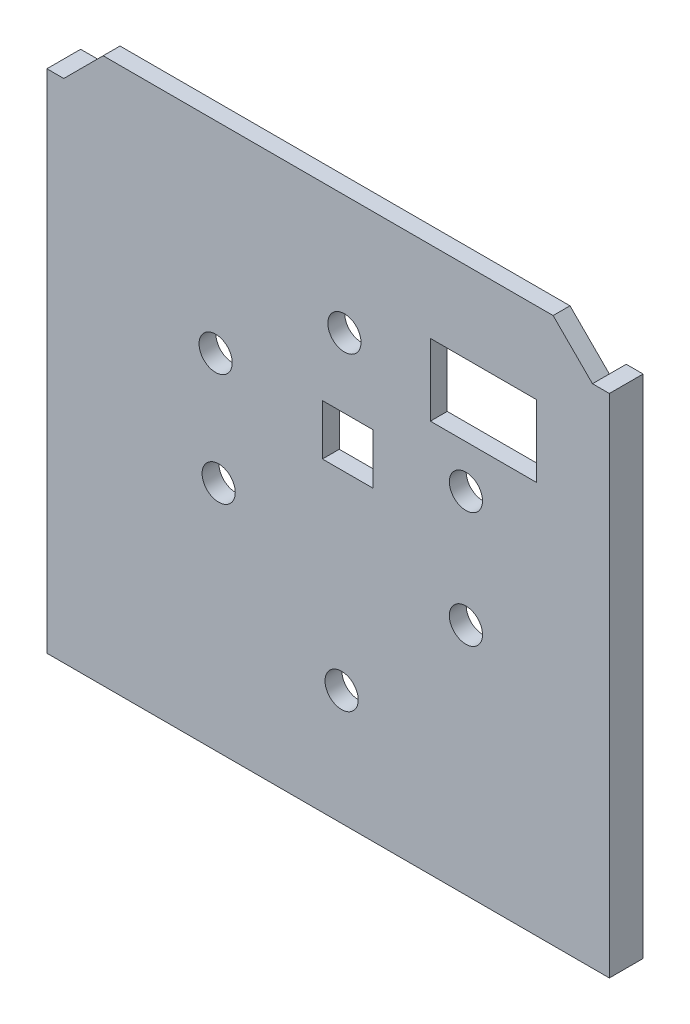
from build123d import *

# Parameters (mm, degrees)
CROQUIS1_R              = 2.950001172
CROQUIS1_W              = 9
CROQUIS1_H              = 9
CROQUIS1_W_2            = 18.849999644
CROQUIS1_H_2            = 12.749999762
SALIENTE_EXTRUIR1_DEPTH = 3
SALIENTE_EXTRUIR6_DEPTH = 3


with BuildPart() as part:
    # Croquis1 → Saliente-Extruir1 (new body)
    with BuildSketch(Plane.XY.offset(-0.156260387)):
        Polygon((51.261125499, 62.988673094), (44.261125499, 69.988673094), (-35.738874501, 69.988673094), (-42.738874501, 62.988673094), (-45.738874501, 62.988673094), (-45.738874501, -27.011326906), (54.261125499, -27.011326906), (54.261125499, 62.988673094), align=None)
        with Locations((7.161124531, 48.770443145)):
            Circle(CROQUIS1_R, mode=Mode.SUBTRACT)
        with Locations((28.761125092, 35.170443896)):
            Circle(CROQUIS1_R, mode=Mode.SUBTRACT)
        with Locations((28.761125092, 14.5704435)):
            Circle(CROQUIS1_R, mode=Mode.SUBTRACT)
        with Locations((6.661127243, -6.529559074)):
            Circle(CROQUIS1_R, mode=Mode.SUBTRACT)
        with Locations((-15.198872503, 14.470443669)):
            Circle(CROQUIS1_R, mode=Mode.SUBTRACT)
        with Locations((-15.738875683, 34.170445595)):
            Circle(CROQUIS1_R, mode=Mode.SUBTRACT)
        with Locations((7.748576734, 31.892113927)):
            Rectangle(CROQUIS1_W, CROQUIS1_H, mode=Mode.SUBTRACT)
        with Locations((31.861125879, 49.188674036)):
            Rectangle(CROQUIS1_W_2, CROQUIS1_H_2, mode=Mode.SUBTRACT)
    extrude(amount=SALIENTE_EXTRUIR1_DEPTH)

    # Croquis9 → Saliente-Extruir6 (add)
    with BuildSketch(Plane(origin=(0, 0, -0.156260387), x_dir=(-1, 0, 0), z_dir=(0, 0, -1))):
        Polygon((-54.261125499, 62.988673094), (-51.261125499, 62.988673094), (-51.261125499, -24.011326906), (42.738874501, -24.011326906), (42.738874501, 62.988673094), (45.738874501, 62.988673094), (45.738874501, -27.011326906), (-54.261125499, -27.011326906), align=None)
    extrude(amount=SALIENTE_EXTRUIR6_DEPTH)


solid = part.part
